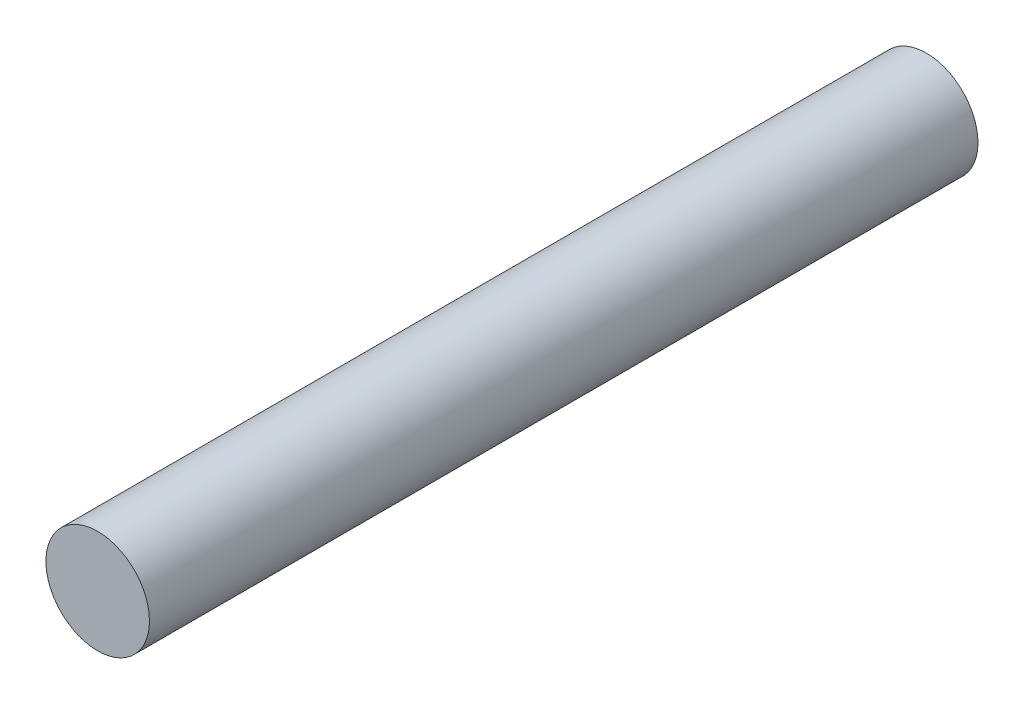
from build123d import *

# Parameters (mm, degrees)
SKETCH_1_R      = 4
EXTRUDE_1_DEPTH = 64


with BuildPart() as part:
    # 草图1 → 凸台-拉伸1 (new body)
    with BuildSketch(Plane.XY):
        Circle(SKETCH_1_R)
    extrude(amount=EXTRUDE_1_DEPTH)


solid = part.part
